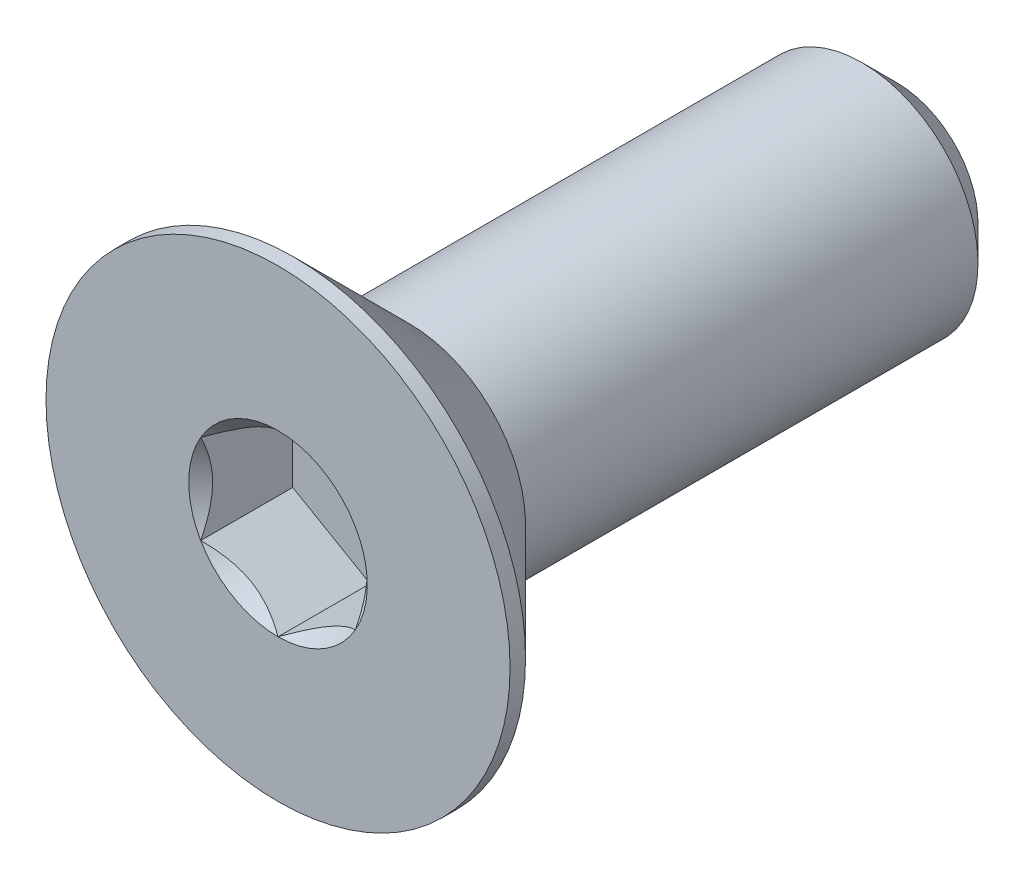
from build123d import *

# Parameters (mm, degrees)
SKETCH3_W          = 8
SKETCH3_H          = 1.5
CHAMFER1_SIZE      = 0.45
CUT_EXTRUDE1_DEPTH = 1.19


with BuildPart() as part:
    # Sketch3 → Revolve1 (revolve)
    with BuildSketch(Plane(origin=(0, 0, 0), x_dir=(0, 0, -1), z_dir=(1, 0, 0))):
        with Locations((0, 0.75)):
            Rectangle(SKETCH3_W, SKETCH3_H)
    revolve(axis=Axis((0, 0, -4), (0, 0, 1)))

    # Chamfer1
    chamfer1_edges = [part.edges().sort_by_distance(p)[0] for p in [
        (0, -1.5, -4),
    ]]
    chamfer(chamfer1_edges, length=CHAMFER1_SIZE)

    # Sketch6 → Revolve2 (revolve)
    with BuildSketch(Plane(origin=(0, 0, 0), x_dir=(0, 0, -1), z_dir=(1, 0, 0))):
        Polygon((-4, 3), (-3.8, 3), (-2.3, 1.5), (-2.3, 0), (-4, 0), align=None)
    revolve(axis=Axis((0, 0, -4), (0, 0, 1)))

    # Sketch8 → Cut-Extrude1 (cut)
    with BuildSketch(Plane.XY.offset(4)):
        Polygon((0, 1.154700538), (-1, 0.577350269), (-1, -0.577350269), (0, -1.154700538), (1, -0.577350269), (1, 0.577350269), align=None)
    extrude(amount=-CUT_EXTRUDE1_DEPTH, mode=Mode.SUBTRACT)

    # Cut-Extrude2 cone 1 section (through the dimple's axis) → Cut-Extrude2 (revolve, cut)
    with BuildSketch(Plane(origin=(0, 0, 4), x_dir=(0, -1, 0), z_dir=(1, 0, 0))):
        Polygon((0, 0), (1.154700538, 0), (0, 1.154700538), align=None)
    revolve(axis=Axis((0, 0, 4), (0, 0, -1)), mode=Mode.SUBTRACT)


solid = part.part
